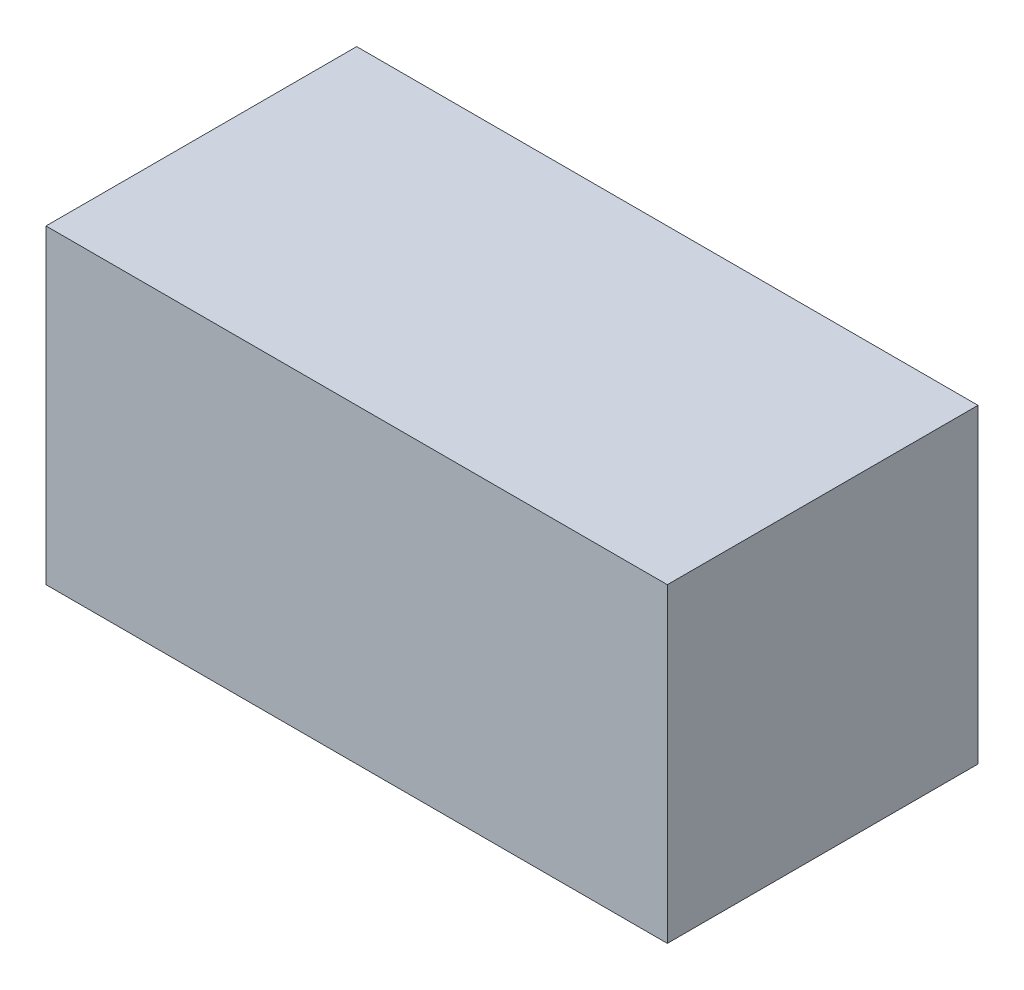
from build123d import *

# Parameters (mm, degrees)
SKETCH1_W           = 100
SKETCH1_H           = 50
BOSS_EXTRUDE1_DEPTH = 50


with BuildPart() as part:
    # Sketch1 → Boss-Extrude1 (new body)
    with BuildSketch(Plane.XY):
        Rectangle(SKETCH1_W, SKETCH1_H)
    extrude(amount=BOSS_EXTRUDE1_DEPTH)


solid = part.part
